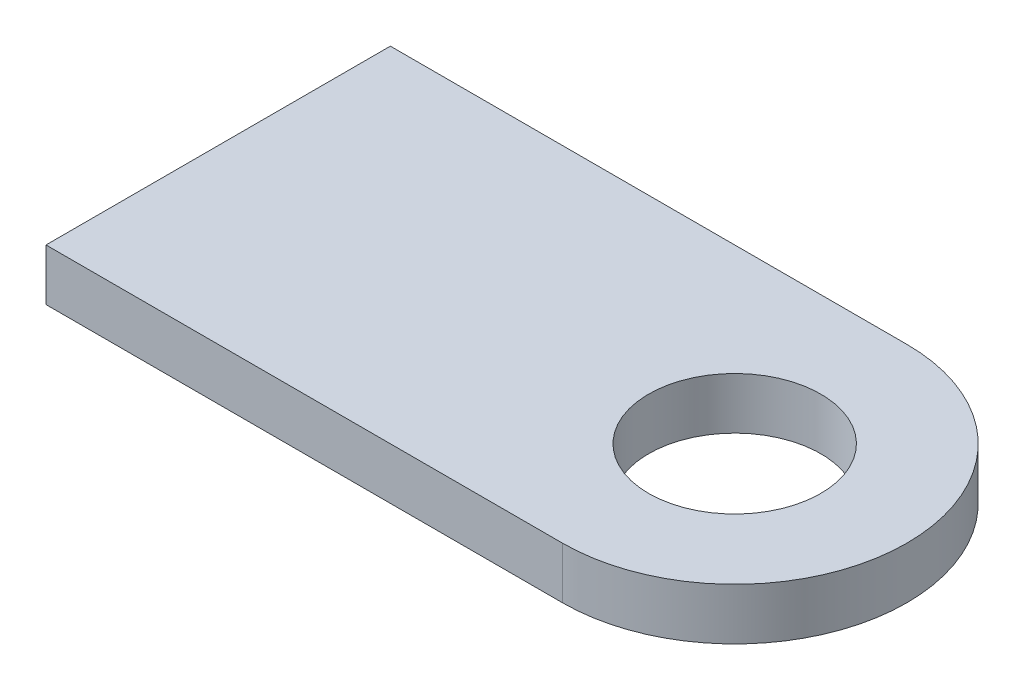
from build123d import *

# Parameters (mm, degrees)
ESQUISSE2_R        = 5
BOSS_EXTRU_1_DEPTH = 3


with BuildPart() as part:
    # Esquisse2 → Boss.-Extru.1 (new body)
    with BuildSketch(Plane(origin=(0, 0, 0), x_dir=(1, 0, 0), z_dir=(0, 1, 0))):
        with BuildLine():
            Line((0, 0), (30, 0))
            ThreePointArc((30, 0), (40, 10), (30, 20))
            Line((30, 20), (0, 20))
            Line((0, 20), (0, 0))
        make_face()
        with Locations(Location((30, 10, 0), (0, 0, 270))):  # turned: the seam where the file's is
            Circle(ESQUISSE2_R, mode=Mode.SUBTRACT)
    extrude(amount=BOSS_EXTRU_1_DEPTH)


solid = part.part
